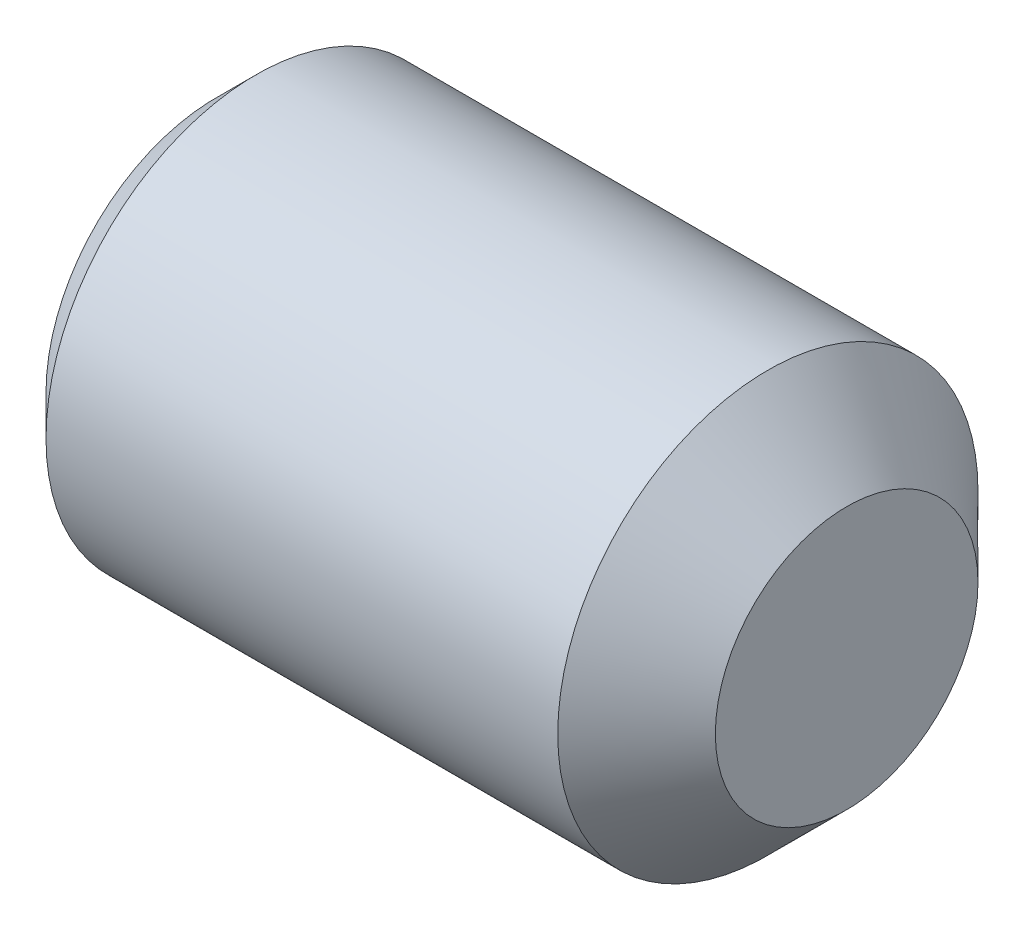
from build123d import *

# Parameters (mm, degrees)
HEXAGONSOCKET_DEPTH = 1.5


with BuildPart() as part:
    # Sketch1 → Base (revolve)
    with BuildSketch(Plane.XY):
        Polygon((0, 0), (6, 0), (6, 1.25), (5.25, 2), (0.379, 2), (0, 1.621), align=None)
    revolve(axis=Axis((-10.745014543, 0, 0), (1, 0, 0)))

    # Sketch2 → HexagonSocket (cut)
    with BuildSketch(Plane(origin=(0, -0.021932325, 0.010138848), x_dir=(0, 0, 1), z_dir=(-1, 0, 0))):
        Polygon((1.14456169, 0.021932325), (0.567211421, 1.021932325), (-0.587489117, 1.021932325), (-1.164839386, 0.021932325), (-0.587489117, -0.978067675), (0.567211421, -0.978067675), align=None)
    extrude(amount=-HEXAGONSOCKET_DEPTH, mode=Mode.SUBTRACT)

    # Sketch3 → Cut-Revolve1 (revolve, cut)
    with BuildSketch(Plane.XY):
        Polygon((1.5, 1), (2.077350269, 0), (1.5, 0), align=None)
    revolve(axis=Axis((-3.144113667, 0, 0), (1, 0, 0)), mode=Mode.SUBTRACT)


solid = part.part
